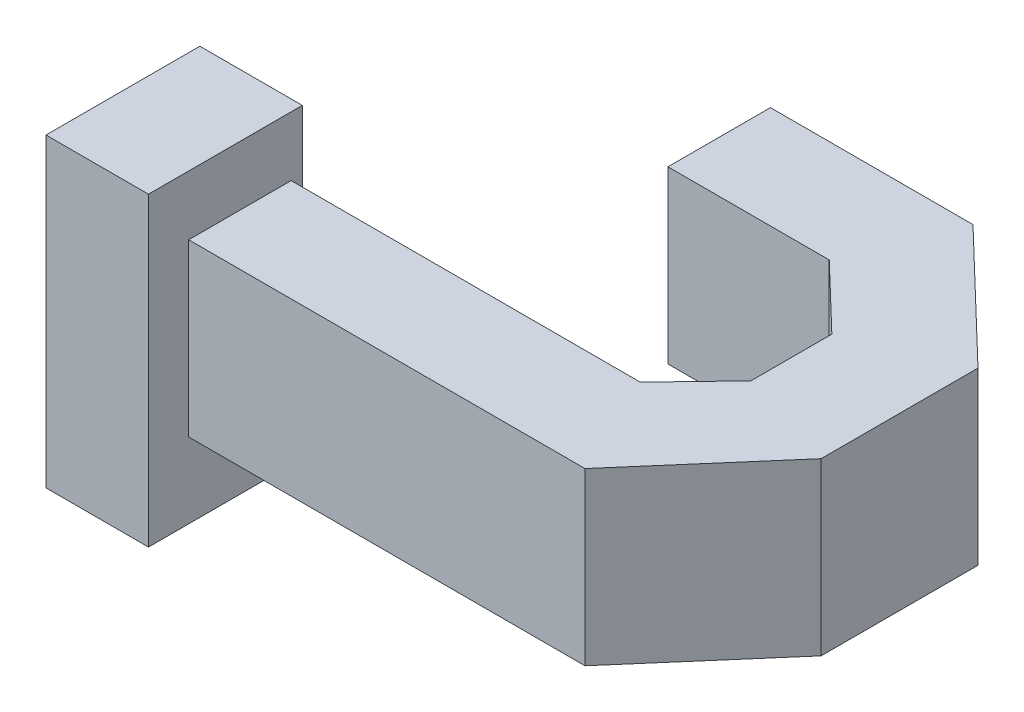
from build123d import *

# Parameters (mm, degrees)
EXTRUDE_1_DEPTH = 5
SKETCH_2_W      = 4.503141041
SKETCH_2_H      = 8.946240201
EXTRUDE_2_DEPTH = 3


with BuildPart() as part:
    # Эскиз1 → Бобышка-Вытянуть1 (new body)
    with BuildSketch(Plane(origin=(0, 0, 0), x_dir=(1, 0, 0), z_dir=(0, 1, 0))):
        Polygon((0, 0), (11.600546573, 0), (14.80537201, 3.707393578), (14.80537201, 8.299672792), (11.09364712, 11.86425352), (5.164556962, 11.86425352), (5.164556962, 8.86425352), (9.886392586, 8.86425352), (11.80537201, 7.021348328), (11.80537201, 4.652272931), (10.218600246, 3), (0, 3), align=None)
    extrude(amount=EXTRUDE_1_DEPTH)

    # Эскиз2 → Бобышка-Вытянуть2 (add)
    with BuildSketch(Plane.ZY):
        with Locations((-1.074738625, 2.270579917)):
            Rectangle(SKETCH_2_W, SKETCH_2_H)
    extrude(amount=EXTRUDE_2_DEPTH)


solid = part.part
